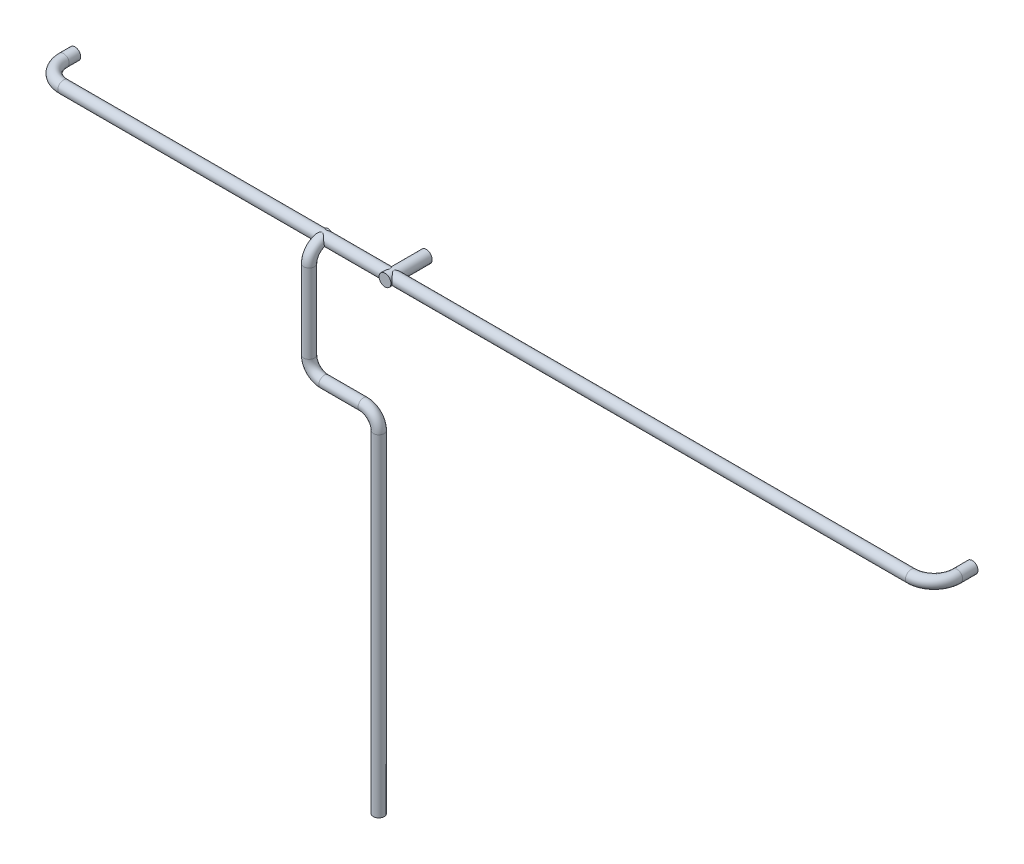
from build123d import *

# Parameters (mm, degrees)
BARRER1_PROFILE_R       = 7.5
CROQUIS22_R             = 7.806571202
SALIENTE_EXTRUIR1_DEPTH = 54
CROQUIS27_R             = 7.100276195


with BuildPart() as part:
    # Barrer1: sweep along a curve in space
    with BuildLine() as barrer1_path:
        Line((0, 0, 0), (0, 0, 15))
        ThreePointArc((0, 0, 15), (8.786796564, 0, 36.213203436), (30, 0, 45))
        Line((30, 0, 45), (1140, 0, 45))
        ThreePointArc((1140, 0, 45), (1161.213203436, 0, 36.213203436), (1170, 0, 15))
        Line((1170, 0, 15), (1170, 0, -5))
    # Barrer1 profile (on start of the path) → Barrer1 (sweep)
    with BuildSketch(Plane.XY):
        Circle(BARRER1_PROFILE_R)
    sweep(path=barrer1_path.line)

    # Croquis22 → Saliente-Extruir1 (add)
    with BuildSketch(Plane(origin=(0, 0, 0), x_dir=(-1, 0, 0), z_dir=(0, 0, -1))):
        with Locations((-460, 0)):
            Circle(CROQUIS22_R)
    extrude(amount=-SALIENTE_EXTRUIR1_DEPTH)

    # Barrer3: sweep along a curve in space
    with BuildLine() as barrer3_path:
        Line((371.624742297, 0, 40), (371.624742297, 0, 45.065102587))
        ThreePointArc((371.624742297, 0, 45.065102587), (371.624742297, -5.857864376, 59.207238211), (371.624742297, -20, 65.065102587))
        Line((371.624742297, -20, 65.065102587), (371.624742297, -123.549378699, 65.065102587))
        ThreePointArc((371.624742297, -123.549378699, 65.065102587), (377.482606674, -137.691514323, 65.065102587), (391.624742297, -143.549378699, 65.065102587))
        Line((391.624742297, -143.549378699, 65.065102587), (442.915360808, -143.549378699, 65.065102587))
        ThreePointArc((442.915360808, -143.549378699, 65.065102587), (457.057496431, -149.407243075, 65.065102587), (462.915360808, -163.549378699, 65.065102587))
        Line((462.915360808, -163.549378699, 65.065102587), (462.915360808, -597.969998302, 65.065102587))
    # Croquis27 → Barrer3 (sweep)
    with BuildSketch(Plane.XY.offset(40)):
        with Locations((371.624742297, 0)):
            Circle(CROQUIS27_R)
    sweep(path=barrer3_path.line)


solid = part.part
